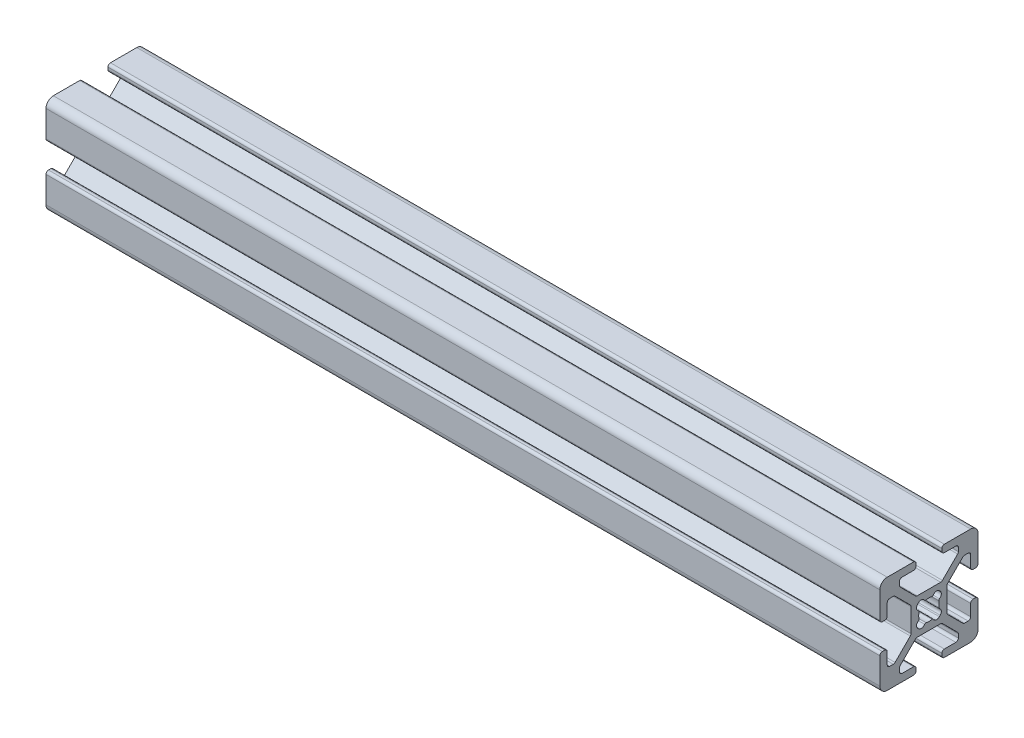
from build123d import *

# Parameters (mm, degrees)
F_20_SERIES_20_2020_1_DEPTH = 170


with BuildPart() as part:
    # Sketch11 → 20_series 20-2020(1) (new body)
    with BuildSketch(Plane(origin=(0, 0, 0), x_dir=(0, 0, -1), z_dir=(1, 0, 0))):
        with BuildLine():
            Line((9.0094, 2.6289), (9.492, 2.6289))
            ThreePointArc((9.492, 2.6289), (9.851210245, 2.777689755), (10, 3.1369))
            Line((10, 3.1369), (10, 8.5014))
            ThreePointArc((10, 8.5014), (9.561070222, 9.561070222), (8.5014, 10))
            Line((8.5014, 10), (3.1369, 10))
            ThreePointArc((3.1369, 10), (2.777689755, 9.851210245), (2.6289, 9.492))
            Line((2.6289, 9.492), (2.6289, 9.0094))
            ThreePointArc((2.6289, 9.0094), (2.777689755, 8.650189755), (3.1369, 8.5014))
            Line((3.1369, 8.5014), (5.4864, 8.5014))
            ThreePointArc((5.4864, 8.5014), (5.845610245, 8.352610245), (5.9944, 7.9934))
            Line((5.9944, 7.9934), (5.9944, 7.264490712))
            ThreePointArc((5.9944, 7.264490712), (5.955730803, 7.070087528), (5.845610245, 6.905280467))
            Line((5.845610245, 6.905280467), (2.747686782, 3.807357004))
            ThreePointArc((2.747686782, 3.807357004), (2.582879721, 3.697236446), (2.388476537, 3.658567249))
            Line((2.388476537, 3.658567249), (-2.388476537, 3.658567249))
            ThreePointArc((-2.388476537, 3.658567249), (-2.582879721, 3.697236446), (-2.747686782, 3.807357004))
            Line((-2.747686782, 3.807357004), (-5.845610245, 6.905280467))
            ThreePointArc((-5.845610245, 6.905280467), (-5.955730803, 7.070087528), (-5.9944, 7.264490712))
            Line((-5.9944, 7.264490712), (-5.9944, 7.9934))
            ThreePointArc((-5.9944, 7.9934), (-5.845610245, 8.352610245), (-5.4864, 8.5014))
            Line((-5.4864, 8.5014), (-3.1369, 8.5014))
            ThreePointArc((-3.1369, 8.5014), (-2.777689755, 8.650189755), (-2.6289, 9.0094))
            Line((-2.6289, 9.0094), (-2.6289, 9.492))
            ThreePointArc((-2.6289, 9.492), (-2.777689755, 9.851210245), (-3.1369, 10))
            Line((-3.1369, 10), (-8.5014, 10))
            ThreePointArc((-8.5014, 10), (-9.561070222, 9.561070222), (-10, 8.5014))
            Line((-10, 8.5014), (-10, 3.1369))
            ThreePointArc((-10, 3.1369), (-9.851210245, 2.777689755), (-9.492, 2.6289))
            Line((-9.492, 2.6289), (-9.0094, 2.6289))
            ThreePointArc((-9.0094, 2.6289), (-8.650189755, 2.777689755), (-8.5014, 3.1369))
            Line((-8.5014, 3.1369), (-8.5014, 5.4864))
            ThreePointArc((-8.5014, 5.4864), (-8.352610245, 5.845610245), (-7.9934, 5.9944))
            Line((-7.9934, 5.9944), (-7.264490712, 5.9944))
            ThreePointArc((-7.264490712, 5.9944), (-7.070087528, 5.955730803), (-6.905280467, 5.845610245))
            Line((-6.905280467, 5.845610245), (-3.807357004, 2.747686782))
            ThreePointArc((-3.807357004, 2.747686782), (-3.697236446, 2.582879721), (-3.658567249, 2.388476537))
            Line((-3.658567249, 2.388476537), (-3.658567249, -2.388476537))
            ThreePointArc((-3.658567249, -2.388476537), (-3.697236446, -2.582879721), (-3.807357004, -2.747686782))
            Line((-3.807357004, -2.747686782), (-6.905280467, -5.845610245))
            ThreePointArc((-6.905280467, -5.845610245), (-7.070087528, -5.955730803), (-7.264490712, -5.9944))
            Line((-7.264490712, -5.9944), (-7.9934, -5.9944))
            ThreePointArc((-7.9934, -5.9944), (-8.352610245, -5.845610245), (-8.5014, -5.4864))
            Line((-8.5014, -5.4864), (-8.5014, -3.1369))
            ThreePointArc((-8.5014, -3.1369), (-8.650189755, -2.777689755), (-9.0094, -2.6289))
            Line((-9.0094, -2.6289), (-9.492, -2.6289))
            ThreePointArc((-9.492, -2.6289), (-9.851210245, -2.777689755), (-10, -3.1369))
            Line((-10, -3.1369), (-10, -8.5014))
            ThreePointArc((-10, -8.5014), (-9.561070222, -9.561070222), (-8.5014, -10))
            Line((-8.5014, -10), (-3.1369, -10))
            ThreePointArc((-3.1369, -10), (-2.777689755, -9.851210245), (-2.6289, -9.492))
            Line((-2.6289, -9.492), (-2.6289, -9.0094))
            ThreePointArc((-2.6289, -9.0094), (-2.777689755, -8.650189755), (-3.1369, -8.5014))
            Line((-3.1369, -8.5014), (-5.4864, -8.5014))
            ThreePointArc((-5.4864, -8.5014), (-5.845610245, -8.352610245), (-5.9944, -7.9934))
            Line((-5.9944, -7.9934), (-5.9944, -7.264490712))
            ThreePointArc((-5.9944, -7.264490712), (-5.955730803, -7.070087528), (-5.845610245, -6.905280467))
            Line((-5.845610245, -6.905280467), (-2.747686782, -3.807357004))
            ThreePointArc((-2.747686782, -3.807357004), (-2.582879721, -3.697236446), (-2.388476537, -3.658567249))
            Line((-2.388476537, -3.658567249), (2.388476537, -3.658567249))
            ThreePointArc((2.388476537, -3.658567249), (2.582879721, -3.697236446), (2.747686782, -3.807357004))
            Line((2.747686782, -3.807357004), (5.845610245, -6.905280467))
            ThreePointArc((5.845610245, -6.905280467), (5.955730803, -7.070087528), (5.9944, -7.264490712))
            Line((5.9944, -7.264490712), (5.9944, -7.9934))
            ThreePointArc((5.9944, -7.9934), (5.845610245, -8.352610245), (5.4864, -8.5014))
            Line((5.4864, -8.5014), (3.1369, -8.5014))
            ThreePointArc((3.1369, -8.5014), (2.777689755, -8.650189755), (2.6289, -9.0094))
            Line((2.6289, -9.0094), (2.6289, -9.492))
            ThreePointArc((2.6289, -9.492), (2.777689755, -9.851210245), (3.1369, -10))
            Line((3.1369, -10), (8.5014, -10))
            ThreePointArc((8.5014, -10), (9.561070222, -9.561070222), (10, -8.5014))
            Line((10, -8.5014), (10, -3.1369))
            ThreePointArc((10, -3.1369), (9.851210245, -2.777689755), (9.492, -2.6289))
            Line((9.492, -2.6289), (9.0094, -2.6289))
            ThreePointArc((9.0094, -2.6289), (8.650189755, -2.777689755), (8.5014, -3.1369))
            Line((8.5014, -3.1369), (8.5014, -5.4864))
            ThreePointArc((8.5014, -5.4864), (8.352610245, -5.845610245), (7.9934, -5.9944))
            Line((7.9934, -5.9944), (7.264490712, -5.9944))
            ThreePointArc((7.264490712, -5.9944), (7.070087528, -5.955730803), (6.905280467, -5.845610245))
            Line((6.905280467, -5.845610245), (3.807357004, -2.747686782))
            ThreePointArc((3.807357004, -2.747686782), (3.697236446, -2.582879721), (3.658567249, -2.388476537))
            Line((3.658567249, -2.388476537), (3.658567249, 2.388476537))
            ThreePointArc((3.658567249, 2.388476537), (3.697236446, 2.582879721), (3.807357004, 2.747686782))
            Line((3.807357004, 2.747686782), (6.905280467, 5.845610245))
            ThreePointArc((6.905280467, 5.845610245), (7.070087528, 5.955730803), (7.264490712, 5.9944))
            Line((7.264490712, 5.9944), (7.9934, 5.9944))
            ThreePointArc((7.9934, 5.9944), (8.352610245, 5.845610245), (8.5014, 5.4864))
            Line((8.5014, 5.4864), (8.5014, 3.1369))
            ThreePointArc((8.5014, 3.1369), (8.650189755, 2.777689755), (9.0094, 2.6289))
        make_face()
        with BuildLine():
            Line((-2.296558466, 2.121727546), (-2.121727546, 2.296558466))
            ThreePointArc((-2.121727546, 2.296558466), (-1.459775814, 2.520126613), (-0.880635441, 2.129282347))
            ThreePointArc((-0.880635441, 2.129282347), (-0.755121693, 2.019456424), (-0.588548999, 2.011151493))
            ThreePointArc((-0.588548999, 2.011151493), (0, 2.0955), (0.588548999, 2.011151493))
            ThreePointArc((0.588548999, 2.011151493), (0.755121693, 2.019456424), (0.880635441, 2.129282347))
            ThreePointArc((0.880635441, 2.129282347), (1.459775814, 2.520126613), (2.121727546, 2.296558466))
            Line((2.121727546, 2.296558466), (2.296558466, 2.121727546))
            ThreePointArc((2.296558466, 2.121727546), (2.520126613, 1.459775814), (2.129282347, 0.880635441))
            ThreePointArc((2.129282347, 0.880635441), (2.019456424, 0.755121693), (2.011151493, 0.588548999))
            ThreePointArc((2.011151493, 0.588548999), (2.0955, 0), (2.011151493, -0.588548999))
            ThreePointArc((2.011151493, -0.588548999), (2.019456424, -0.755121693), (2.129282347, -0.880635441))
            ThreePointArc((2.129282347, -0.880635441), (2.520126613, -1.459775814), (2.296558466, -2.121727546))
            Line((2.296558466, -2.121727546), (2.121727546, -2.296558466))
            ThreePointArc((2.121727546, -2.296558466), (1.459775814, -2.520126613), (0.880635441, -2.129282347))
            ThreePointArc((0.880635441, -2.129282347), (0.755121693, -2.019456424), (0.588548999, -2.011151493))
            ThreePointArc((0.588548999, -2.011151493), (0, -2.0955), (-0.588548999, -2.011151493))
            ThreePointArc((-0.588548999, -2.011151493), (-0.755121693, -2.019456424), (-0.880635441, -2.129282347))
            ThreePointArc((-0.880635441, -2.129282347), (-1.459775814, -2.520126613), (-2.121727546, -2.296558466))
            Line((-2.121727546, -2.296558466), (-2.296558466, -2.121727546))
            ThreePointArc((-2.296558466, -2.121727546), (-2.520126613, -1.459775814), (-2.129282347, -0.880635441))
            ThreePointArc((-2.129282347, -0.880635441), (-2.019456424, -0.755121693), (-2.011151493, -0.588548999))
            ThreePointArc((-2.011151493, -0.588548999), (-2.0955, 0), (-2.011151493, 0.588548999))
            ThreePointArc((-2.011151493, 0.588548999), (-2.019456424, 0.755121693), (-2.129282347, 0.880635441))
            ThreePointArc((-2.129282347, 0.880635441), (-2.520126613, 1.459775814), (-2.296558466, 2.121727546))
        make_face(mode=Mode.SUBTRACT)
    extrude(amount=F_20_SERIES_20_2020_1_DEPTH)


solid = part.part
